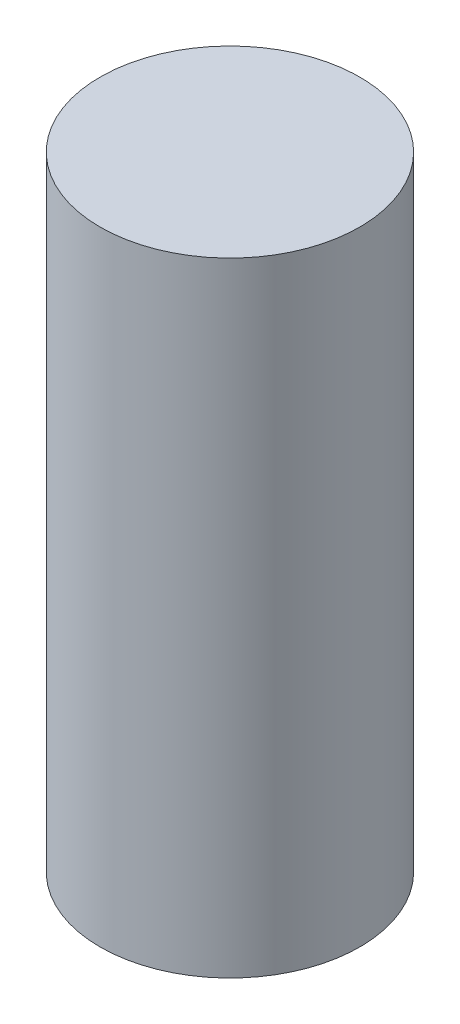
from build123d import *

# Parameters (mm, degrees)
SKETCH1_R           = 12.5
BOSS_EXTRUDE1_DEPTH = 60


with BuildPart() as part:
    # Sketch1 → Boss-Extrude1 (new body)
    with BuildSketch(Plane(origin=(0, 0, 0), x_dir=(1, 0, 0), z_dir=(0, 1, 0))):
        Circle(SKETCH1_R)
    extrude(amount=BOSS_EXTRUDE1_DEPTH)


solid = part.part
